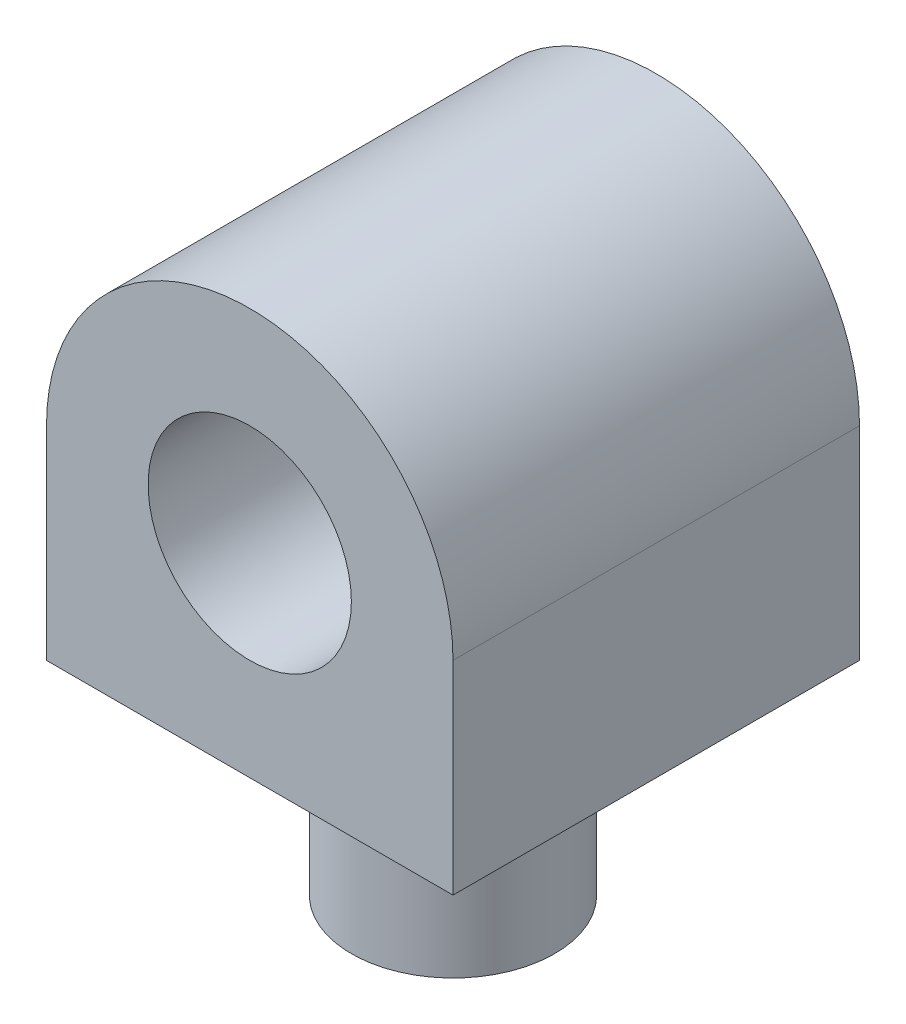
from build123d import *

# Parameters (mm, degrees)
SKETCH1_LINK5_R     = 15
BOSS_EXTRUDE1_DEPTH = 30
SKETCH2_LINK5_R     = 15
BOSS_EXTRUDE2_DEPTH = 30


with BuildPart() as part:
    # sketch1_link5 → Boss-Extrude1 (new body, symmetric)
    with BuildSketch(Plane.XY):
        with BuildLine():
            Line((-30, 0), (-30, -30))
            Line((-30, -30), (30, -30))
            Line((30, -30), (30, 0))
            ThreePointArc((30, 0), (0, 30), (-30, 0))
        make_face()
        Circle(SKETCH1_LINK5_R, mode=Mode.SUBTRACT)
    extrude(amount=BOSS_EXTRUDE1_DEPTH, both=True)

    # sketch2_link5 → Boss-Extrude2 (add)
    with BuildSketch(Plane.XZ.offset(30)):
        Circle(SKETCH2_LINK5_R)
    extrude(amount=BOSS_EXTRUDE2_DEPTH)


solid = part.part
